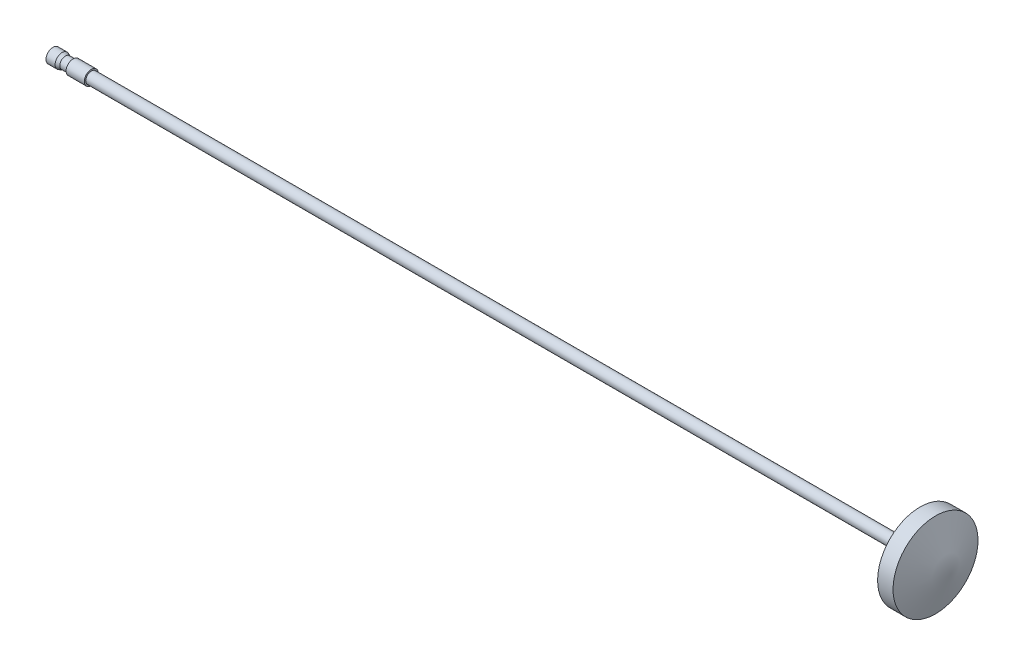
from build123d import *


with BuildPart() as part:
    # Sketch1 → Revolve1 (revolve)
    with BuildSketch(Plane.XY):
        Polygon((-48.04, 0.625), (-47.21, 0.625), (-47.1968767, 0.775), (-45.1968767, 0.775), (-45.183753401, 0.625), (46.02, 0.625), (46.02, 4.675), (47.72, 4.675), (49.42, 0), (-49.42, 0), (-49.42, 0.625), (-49.4068767, 0.775), (-48.4068767, 0.775), align=None)
    revolve(axis=Axis((-49.42, 0, 0), (1, 0, 0)))


solid = part.part
